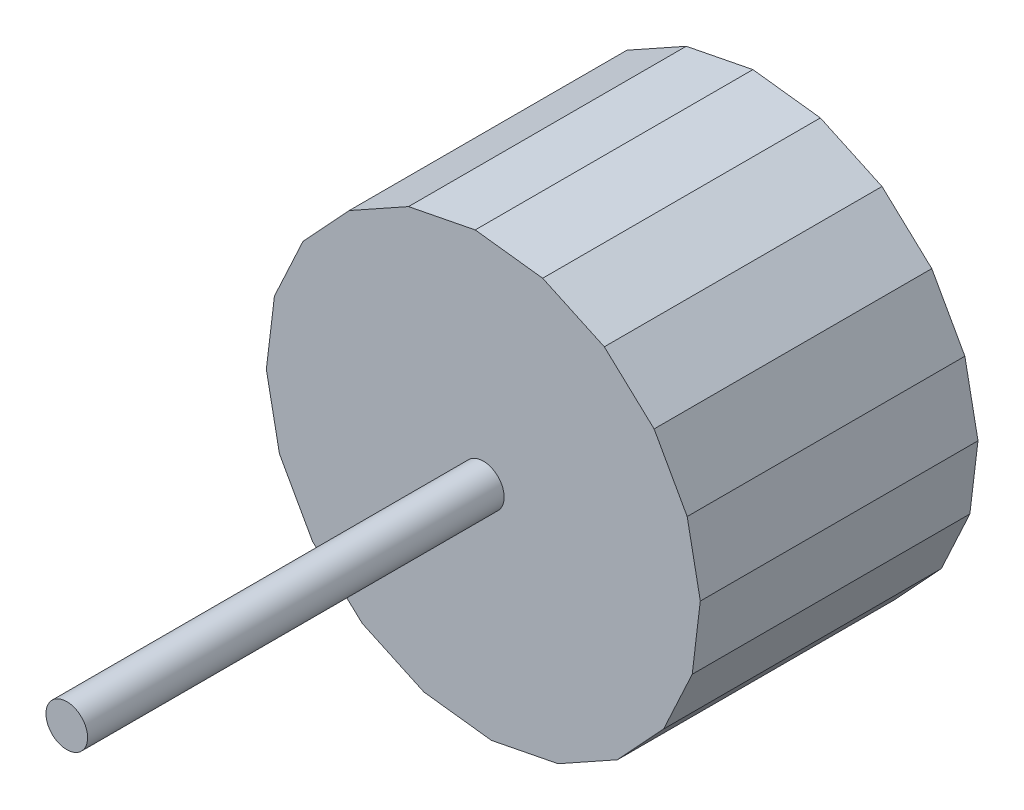
from build123d import *

# Parameters (mm, degrees)
RESSALTO_EXTRUS_O1_DEPTH = 20
CASCA1_T                 = -1.5
ESBO_O2_R                = 1.5
RESSALTO_EXTRUS_O2_DEPTH = 30


with BuildPart() as part:
    # Esboço1 → Ressalto-extrusão1 (new body)
    with BuildSketch(Plane.XY):
        Polygon((-12.986930378, 8.7142726), (-15.044163089, 4.274583549), (-15.628768299, -0.583531522), (-14.683520775, -5.384526462), (-12.300947932, -9.658446435), (-8.7142726, -12.986930378), (-4.274583549, -15.044163089), (0.583531522, -15.628768299), (5.384526462, -14.683520775), (9.658446435, -12.300947932), (12.986930378, -8.7142726), (15.044163089, -4.274583549), (15.628768299, 0.583531522), (14.683520775, 5.384526462), (12.300947932, 9.658446435), (8.7142726, 12.986930378), (4.274583549, 15.044163089), (-0.583531522, 15.628768299), (-5.384526462, 14.683520775), (-9.658446435, 12.300947932), align=None)
    extrude(amount=RESSALTO_EXTRUS_O1_DEPTH)

    # Casca1
    casca1_openings = [part.faces().sort_by_distance(p)[0] for p in [
        (0, 0, 0),
    ]]
    offset(amount=CASCA1_T, openings=casca1_openings, kind=Kind.INTERSECTION)

    # Esboço2 → Ressalto-extrusão2 (add)
    with BuildSketch(Plane.XY.offset(20)):
        Circle(ESBO_O2_R)
    extrude(amount=RESSALTO_EXTRUS_O2_DEPTH)


solid = part.part
